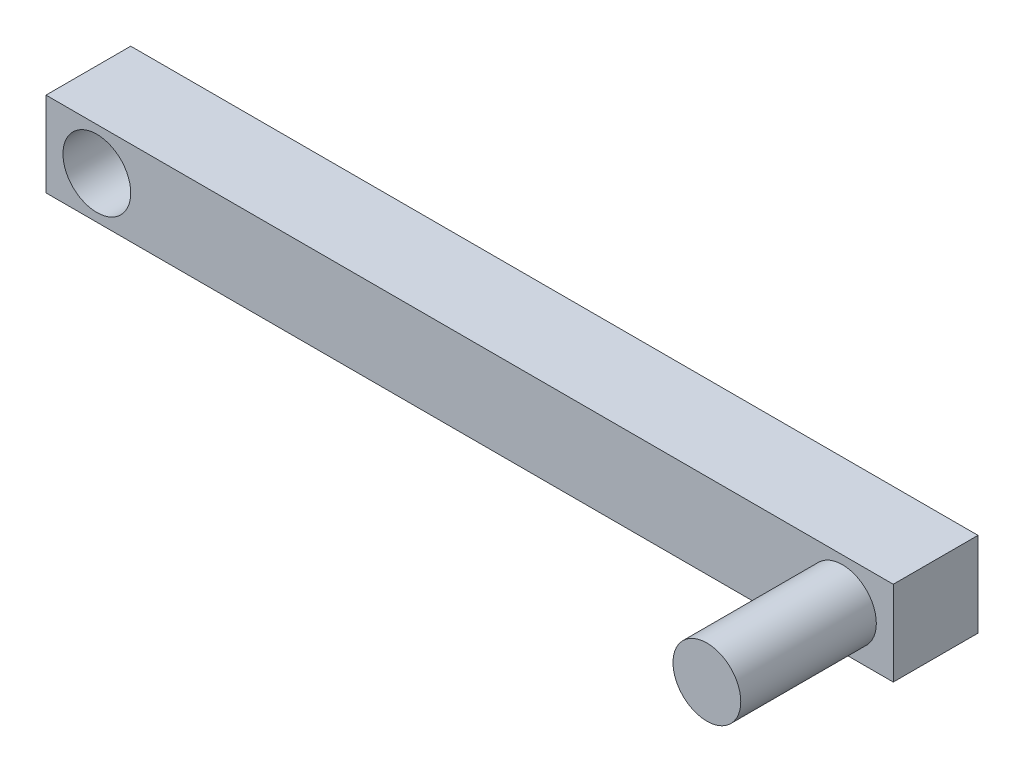
from build123d import *

# Parameters (mm, degrees)
SKETCH_2_W          = 50
SKETCH_2_H          = 5
EXTRUDE_1_DEPTH     = 5
SKETCH_3_R          = 2
CUT_EXTRUDE_1_DEPTH = 5
SKETCH_4_R          = 2
EXTRUDE_2_DEPTH     = 8


with BuildPart() as part:
    # 草图2 → 凸台-拉伸1 (new body)
    with BuildSketch(Plane.XY):
        with Locations((-16.04, 2.5)):
            Rectangle(SKETCH_2_W, SKETCH_2_H)
    extrude(amount=EXTRUDE_1_DEPTH)

    # 草图3 → 切除-拉伸1 (cut)
    with BuildSketch(Plane.XY.offset(5)):
        with Locations((-38.04, 2.5)):
            Circle(SKETCH_3_R)
    extrude(amount=-CUT_EXTRUDE_1_DEPTH, mode=Mode.SUBTRACT)

    # 草图4 → 凸台-拉伸2 (add)
    with BuildSketch(Plane.XY.offset(5)):
        with Locations((5.96, 2.5)):
            Circle(SKETCH_4_R)
    extrude(amount=EXTRUDE_2_DEPTH)


solid = part.part
